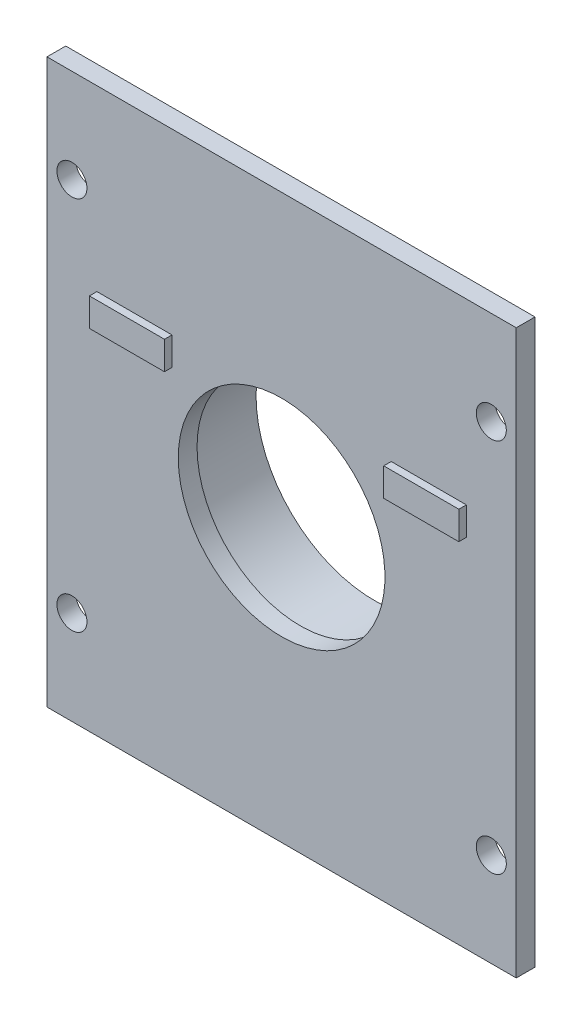
from build123d import *

# Parameters (mm, degrees)
SKETCH3_W           = 63.5
SKETCH3_H           = 76.2
BOSS_EXTRUDE2_DEPTH = 2.54
SKETCH4_R           = 17.270000004
SKETCH4_R_2         = 16.000000004
BOSS_EXTRUDE3_DEPTH = 10
SKETCH5_R           = 13.983999972
CUT_EXTRUDE1_DEPTH  = 10.0076
SKETCH8_R           = 2.032
CUT_EXTRUDE2_DEPTH  = 3.54
SKETCH9_W           = 10.16
SKETCH9_H           = 3.81
BOSS_EXTRUDE4_DEPTH = 1.016


with BuildPart() as part:
    # Sketch3 → Boss-Extrude2 (new body)
    with BuildSketch(Plane.XY):
        with Locations((31.75, 38.1)):
            Rectangle(SKETCH3_W, SKETCH3_H)
    extrude(amount=BOSS_EXTRUDE2_DEPTH)

    # Sketch4 → Boss-Extrude3 (add)
    with BuildSketch(Plane(origin=(0, 0, 0), x_dir=(-1, 0, 0), z_dir=(0, 0, -1))):
        with Locations((-31.75, 38.1)):
            Circle(SKETCH4_R)
        with Locations((-31.75, 38.1)):
            Circle(SKETCH4_R_2, mode=Mode.SUBTRACT)
    extrude(amount=BOSS_EXTRUDE3_DEPTH)

    # Sketch5 → Cut-Extrude1 (cut)
    with BuildSketch(Plane(origin=(0, 0, 0), x_dir=(-1, 0, 0), z_dir=(0, 0, -1))):
        with Locations((-31.75, 38.1)):
            Circle(SKETCH5_R)
    extrude(amount=-CUT_EXTRUDE1_DEPTH, mode=Mode.SUBTRACT)

    # Sketch8 → Cut-Extrude2 (cut, through all)
    with BuildSketch(Plane(origin=(0, 0, 0), x_dir=(-1, 0, 0), z_dir=(0, 0, -1))):
        with Locations((-3.375, 63.5)):
            Circle(SKETCH8_R)
        with Locations((-60.125, 63.5)):
            Circle(SKETCH8_R)
        with Locations((-60.125, 12.7)):
            Circle(SKETCH8_R)
        with Locations((-3.375, 12.7)):
            Circle(SKETCH8_R)
    extrude(amount=-CUT_EXTRUDE2_DEPTH, mode=Mode.SUBTRACT)

    # Sketch9 → Boss-Extrude4 (add)
    with BuildSketch(Plane.XY.offset(2.54)):
        with Locations((51.6636, 50.165)):
            Rectangle(SKETCH9_W, SKETCH9_H)
        with Locations((11.8364, 50.165)):
            Rectangle(SKETCH9_W, SKETCH9_H)
    extrude(amount=BOSS_EXTRUDE4_DEPTH)


solid = part.part
